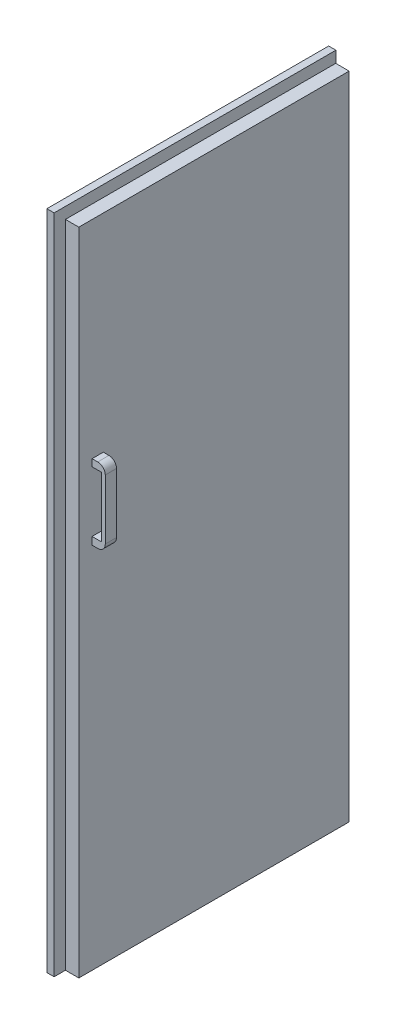
from build123d import *

# Parameters (mm, degrees)
SKETCH1_W            = 54.758446478
SKETCH1_H            = 717
BOSS_EXTRUDE1_DEPTH  = 1725
SKETCH2_W            = 19.21757675
SKETCH2_H            = 1725
BOSS_EXTRUDE2_DEPTH  = 30
SKETCH3_W            = 19.21757675
SKETCH3_H            = 747.470855808
BOSS_EXTRUDE3_DEPTH  = 30
SKETCH5_W            = 704.182305872
SKETCH5_H            = 1697.425748722
CUT_EXTRUDE1_DEPTH   = 8.60534571
SKETCH6_W            = 704.182305872
SKETCH6_H            = 43.914333375
BOSS_EXTRUDE5_DEPTH  = 9
SKETCH7_W            = 29.914870165
SKETCH7_H            = 20.630944942
BOSS_EXTRUDE6_DEPTH  = 35
SKETCH8_W            = 29.914870164
SKETCH8_H            = 20.630944941
BOSS_EXTRUDE7_DEPTH  = 35
SKETCH9_W            = 27.336002047
SKETCH9_H            = 231.066583342
BOSS_EXTRUDE8_DEPTH  = 10
SKETCH10_W           = 2.578868118
SKETCH10_H           = 20.630944942
CUT_EXTRUDE2_DEPTH   = 35
SKETCH11_W           = 2.578868117
SKETCH11_H           = 20.630944941
CUT_EXTRUDE3_DEPTH   = 35
FILLET2_R            = 20
FILLET3_R            = 20
SKETCH12_W           = 29.76753668
SKETCH12_H           = 18.691243962
SKETCH12_H_2         = 20.075780552
BOSS_EXTRUDE9_DEPTH  = 25
SKETCH13_W           = 29.76753668
SKETCH13_H           = 198.681000631
BOSS_EXTRUDE10_DEPTH = 10
FILLET4_R            = 20
FILLET5_R            = 20


with BuildPart() as part:
    # Sketch1 → Boss-Extrude1 (new body)
    with BuildSketch(Plane(origin=(0, 0, 0), x_dir=(1, 0, 0), z_dir=(0, 1, 0))):
        with Locations((27.379223239, -358.5)):
            Rectangle(SKETCH1_W, SKETCH1_H)
    extrude(amount=BOSS_EXTRUDE1_DEPTH)

    # Sketch2 → Boss-Extrude2 (add)
    with BuildSketch(Plane.XY.offset(717)):
        with Locations((9.608788375, 862.5)):
            Rectangle(SKETCH2_W, SKETCH2_H)
    extrude(amount=BOSS_EXTRUDE2_DEPTH)

    # Sketch3 → Boss-Extrude3 (add)
    with BuildSketch(Plane(origin=(0, 1725, 0), x_dir=(1, 0, 0), z_dir=(0, 1, 0))):
        with Locations((9.608788375, -373.264572096)):
            Rectangle(SKETCH3_W, SKETCH3_H)
    extrude(amount=BOSS_EXTRUDE3_DEPTH)

    # Sketch5 → Cut-Extrude1 (cut)
    with BuildSketch(Plane.ZY):
        with Locations((352.091152936, 896.687125639)):
            Rectangle(SKETCH5_W, SKETCH5_H)
    extrude(amount=-CUT_EXTRUDE1_DEPTH, mode=Mode.SUBTRACT)

    # Sketch6 → Boss-Extrude5 (add)
    with BuildSketch(Plane.ZY.offset(-8.60534571)):
        with Locations((352.091152936, 969.31583271)):
            Rectangle(SKETCH6_W, SKETCH6_H)
    extrude(amount=BOSS_EXTRUDE5_DEPTH)

    # Sketch7 → Boss-Extrude6 (add)
    with BuildSketch(Plane.ZY.offset(-8.60534571)):
        with Locations((647.577834423, 1083.33925491)):
            Rectangle(SKETCH7_W, SKETCH7_H)
    extrude(amount=BOSS_EXTRUDE6_DEPTH)

    # Sketch8 → Boss-Extrude7 (add)
    with BuildSketch(Plane.ZY.offset(-8.60534571)):
        with Locations((644.998966305, 872.90361651)):
            Rectangle(SKETCH8_W, SKETCH8_H)
    extrude(amount=BOSS_EXTRUDE7_DEPTH)

    # Sketch9 → Boss-Extrude8 (add)
    with BuildSketch(Plane.ZY.offset(26.39465429)):
        with Locations((646.288400364, 978.12143571)):
            Rectangle(SKETCH9_W, SKETCH9_H)
    extrude(amount=BOSS_EXTRUDE8_DEPTH)

    # Sketch10 → Cut-Extrude2 (cut)
    with BuildSketch(Plane.ZY.offset(26.39465429)):
        with Locations((661.245835446, 1083.33925491)):
            Rectangle(SKETCH10_W, SKETCH10_H)
    extrude(amount=-CUT_EXTRUDE2_DEPTH, mode=Mode.SUBTRACT)

    # Sketch11 → Cut-Extrude3 (cut)
    with BuildSketch(Plane.ZY.offset(26.39465429)):
        with Locations((631.330965282, 872.90361651)):
            Rectangle(SKETCH11_W, SKETCH11_H)
    extrude(amount=-CUT_EXTRUDE3_DEPTH, mode=Mode.SUBTRACT)

    # Fillet2
    fillet2_edges = [part.edges().sort_by_distance(p)[0] for p in [
        (-36.39465429, 862.588144039, 646.288400364),
    ]]
    fillet(fillet2_edges, radius=FILLET2_R)

    # Fillet3
    fillet3_edges = [part.edges().sort_by_distance(p)[0] for p in [
        (-36.39465429, 1093.654727381, 646.288400364),
    ]]
    fillet(fillet3_edges, radius=FILLET3_R)

    # Sketch12 → Boss-Extrude9 (add)
    with BuildSketch(Plane(origin=(54.758446478, 0, 0), x_dir=(0, 0, -1), z_dir=(1, 0, 0))):
        with Locations((-666.999193263, 1166.168231526)):
            Rectangle(SKETCH12_W, SKETCH12_H)
        with Locations((-666.999193263, 986.870743152)):
            Rectangle(SKETCH12_W, SKETCH12_H_2)
    extrude(amount=BOSS_EXTRUDE9_DEPTH)

    # Sketch13 → Boss-Extrude10 (add)
    with BuildSketch(Plane(origin=(79.758446478, 0, 0), x_dir=(0, 0, -1), z_dir=(1, 0, 0))):
        with Locations((-666.999193263, 1076.173353192)):
            Rectangle(SKETCH13_W, SKETCH13_H)
    extrude(amount=BOSS_EXTRUDE10_DEPTH)

    # Fillet4
    fillet4_edges = [part.edges().sort_by_distance(p)[0] for p in [
        (89.758446478, 1175.513853507, 666.999193263),
    ]]
    fillet(fillet4_edges, radius=FILLET4_R)

    # Fillet5
    fillet5_edges = [part.edges().sort_by_distance(p)[0] for p in [
        (89.758446478, 976.832852876, 666.999193263),
    ]]
    fillet(fillet5_edges, radius=FILLET5_R)


solid = part.part
